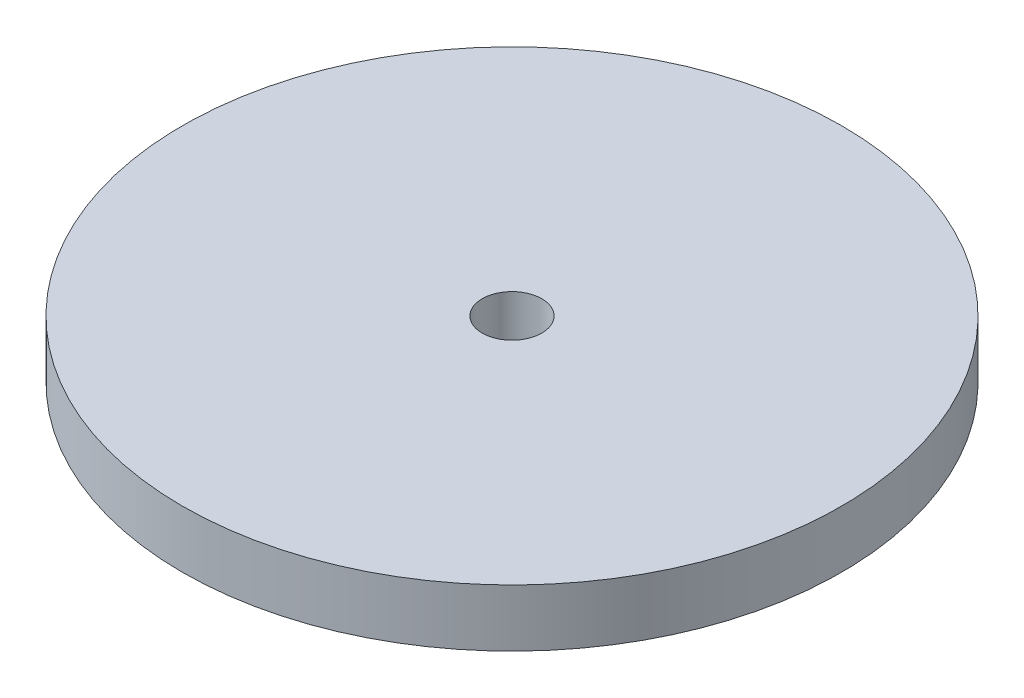
from build123d import *

# Parameters (mm, degrees)
SKETCH1_R           = 36.5125
SKETCH1_R_2         = 3.302
BOSS_EXTRUDE1_DEPTH = 6.35


with BuildPart() as part:
    # Sketch1 → Boss-Extrude1 (new body)
    with BuildSketch(Plane(origin=(0, 0, 0), x_dir=(1, 0, 0), z_dir=(0, 1, 0))):
        Circle(SKETCH1_R)
        Circle(SKETCH1_R_2, mode=Mode.SUBTRACT)
    extrude(amount=BOSS_EXTRUDE1_DEPTH)


solid = part.part
